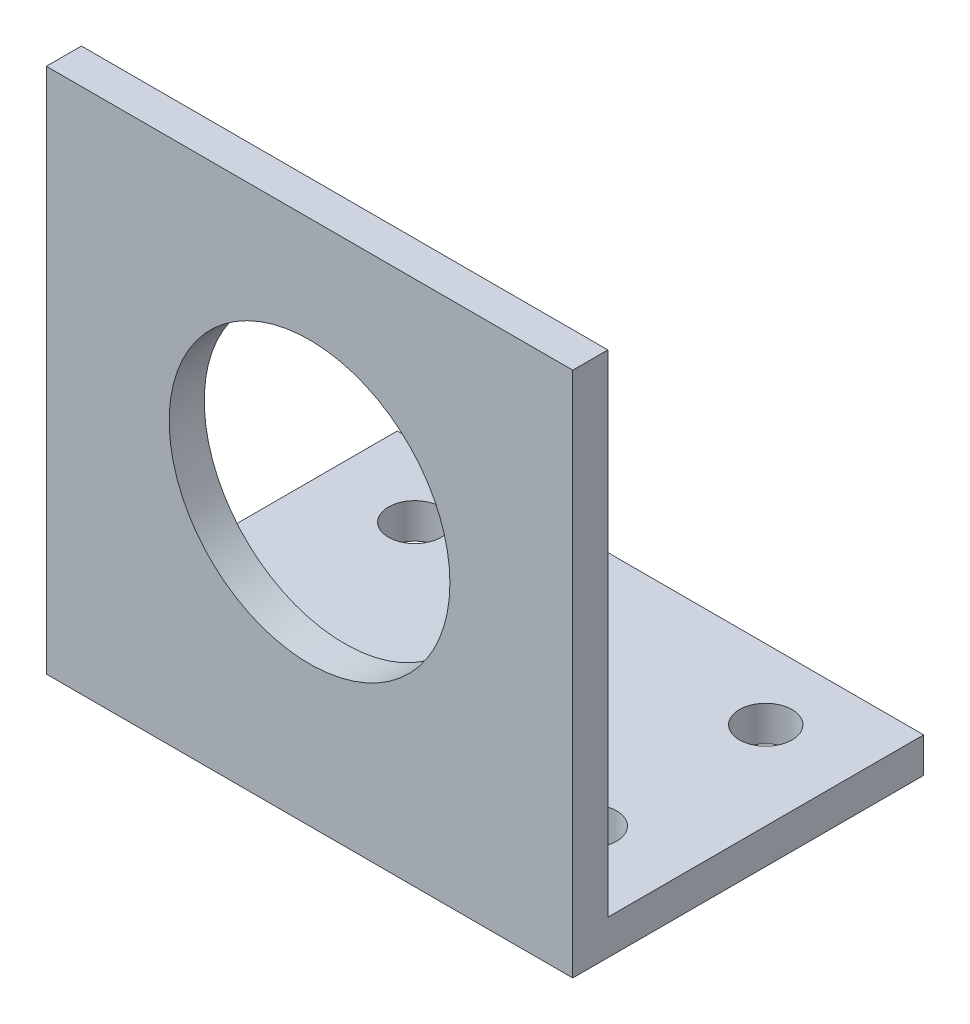
from build123d import *

# Parameters (mm, degrees)
EXTRUDE_1_DEPTH     = 20
SKETCH_9_W          = 35
SKETCH_9_H          = 3
EXTRUDE_2_DEPTH     = 5
SKETCH_10_W         = 3
SKETCH_10_H         = 35
EXTRUDE_3_DEPTH     = 5
SKETCH_11_R         = 8
CUT_EXTRUDE_4_DEPTH = 8
SKETCH_12_W         = 30
SKETCH_12_H         = 3
CUT_EXTRUDE_5_DEPTH = 18
SKETCH_13_W         = 30
SKETCH_13_H         = 17
CUT_EXTRUDE_6_DEPTH = 1
SKETCH_14_W         = 30
SKETCH_14_H         = 36
CUT_EXTRUDE_7_DEPTH = 1
SKETCH_15_R         = 1.5
CUT_EXTRUDE_8_DEPTH = 2
SKETCH_17_W         = 39.353314789
SKETCH_17_H         = 5.702998022
CUT_EXTRUDE_9_DEPTH = 8


with BuildPart() as part:
    # 草图1 → 凸台-拉伸1 (new body)
    with BuildSketch(Plane(origin=(0, 0, 0), x_dir=(0, 0, -1), z_dir=(1, 0, 0))):
        Polygon((0, 0), (0, 38), (3, 38), (3, 3), (38, 3), (38, 0), align=None)
    extrude(amount=EXTRUDE_1_DEPTH)

    # 草图9 → 凸台-拉伸2 (add)
    with BuildSketch(Plane(origin=(20, 0, 0), x_dir=(0, 0, -1), z_dir=(1, 0, 0))):
        Polygon((3, 38), (0, 38), (0, 0), (3, 0), (3, 3), align=None)
        with Locations((20.5, 1.5)):
            Rectangle(SKETCH_9_W, SKETCH_9_H)
    extrude(amount=EXTRUDE_2_DEPTH)

    # 草图10 → 凸台-拉伸3 (add)
    with BuildSketch(Plane.ZY):
        with Locations((-1.5, 20.5)):
            Rectangle(SKETCH_10_W, SKETCH_10_H)
        Polygon((0, 0), (0, 3), (-3, 3), (-38, 3), (-38, 0), align=None)
    extrude(amount=EXTRUDE_3_DEPTH)

    # 草图11 → 切除-拉伸4 (cut)
    with BuildSketch(Plane.XY):
        with Locations((10, 16)):
            Circle(SKETCH_11_R)
    extrude(amount=-CUT_EXTRUDE_4_DEPTH, mode=Mode.SUBTRACT)

    # 草图12 → 切除-拉伸5 (cut)
    with BuildSketch(Plane(origin=(0, 0, -38), x_dir=(-1, 0, 0), z_dir=(0, 0, -1))):
        with Locations((-10, 1.5)):
            Rectangle(SKETCH_12_W, SKETCH_12_H)
    extrude(amount=-CUT_EXTRUDE_5_DEPTH, mode=Mode.SUBTRACT)

    # 草图13 → 切除-拉伸6 (cut)
    with BuildSketch(Plane(origin=(0, 3, 0), x_dir=(1, 0, 0), z_dir=(0, 1, 0))):
        with Locations((10, 11.5)):
            Rectangle(SKETCH_13_W, SKETCH_13_H)
    extrude(amount=-CUT_EXTRUDE_6_DEPTH, mode=Mode.SUBTRACT)

    # 草图14 → 切除-拉伸7 (cut)
    with BuildSketch(Plane(origin=(0, 0, -3), x_dir=(-1, 0, 0), z_dir=(0, 0, -1))):
        with Locations((-10, 20)):
            Rectangle(SKETCH_14_W, SKETCH_14_H)
    extrude(amount=-CUT_EXTRUDE_7_DEPTH, mode=Mode.SUBTRACT)

    # 草图15 → 切除-拉伸8 (cut)
    with BuildSketch(Plane(origin=(0, 2, 0), x_dir=(1, 0, 0), z_dir=(0, 1, 0))):
        with Locations((20, 6)):
            Circle(SKETCH_15_R)
        with Locations((0, 6)):
            Circle(SKETCH_15_R)
        with Locations((0, 16)):
            Circle(SKETCH_15_R)
        with Locations((20, 16)):
            Circle(SKETCH_15_R)
    extrude(amount=-CUT_EXTRUDE_8_DEPTH, mode=Mode.SUBTRACT)

    # 草图17 → 切除-拉伸9 (cut)
    with BuildSketch(Plane(origin=(0, 38, 0), x_dir=(1, 0, 0), z_dir=(0, 1, 0))):
        with Locations((8.215909563, 1.4252762)):
            Rectangle(SKETCH_17_W, SKETCH_17_H)
    extrude(amount=-CUT_EXTRUDE_9_DEPTH, mode=Mode.SUBTRACT)


solid = part.part
